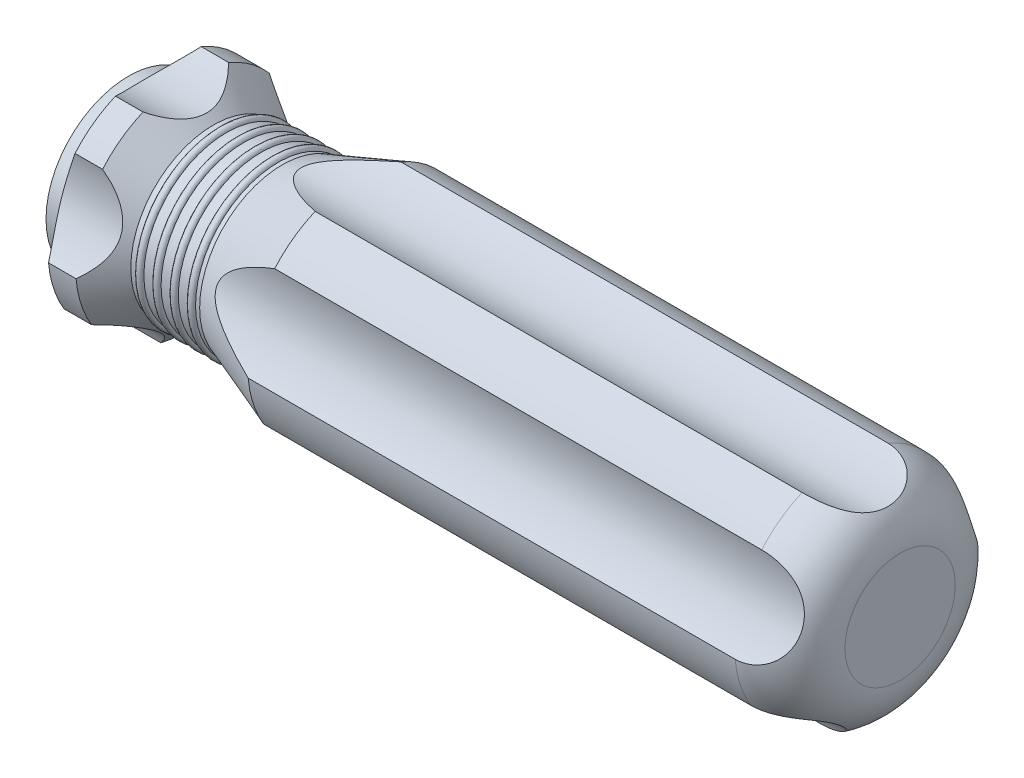
from build123d import *

# Parameters (mm, degrees)
SKETCH2_R          = 0.25
LPATTERN1_COUNT    = 4
LPATTERN1_PITCH    = 1.25
SKETCH3_R          = 6
CUT_EXTRUDE1_DEPTH = 57
CIRPATTERN1_COUNT  = 5
SKETCH4_R          = 1.5
CUT_EXTRUDE2_DEPTH = 30


with BuildPart() as part:
    # Sketch1 → Revolve1 (revolve)
    with BuildSketch(Plane.XY):
        with BuildLine():
            Line((0, 6), (1, 6))
            Line((1, 6), (2.154700538, 8))
            Line((2.154700538, 8), (4.154700538, 8))
            Line((4.154700538, 8), (6.154700538, 6))
            Line((6.154700538, 6), (11.154700538, 6))
            Line((11.154700538, 6), (16.649655377, 8))
            Line((16.649655377, 8), (52, 8))
            ThreePointArc((52, 8), (54.828427125, 6.828427125), (56, 4))
            Line((56, 4), (56, 0))
            Line((56, 0), (0, 0))
            Line((0, 0), (0, 6))
        make_face()
    revolve(axis=Axis((0, 0, 0), (1, 0, 0)))

    # Sketch2 → Revolve2 (revolve)
    with BuildSketch(Plane.XY):
        with Locations((6.854700538, 6)):
            Circle(SKETCH2_R)
    revolve2 = revolve(axis=Axis((0, 0, 0), (1, 0, 0)))

    # LPattern1: Revolve2 ×4
    with Locations(*[(i * LPATTERN1_PITCH, 0, 0) for i in range(1, LPATTERN1_COUNT)]):
        add(revolve2)

    # Sketch3 → Cut-Extrude1 (cut, through all)
    with BuildSketch(Plane.ZY):
        with Locations((0, 12.5)):
            Circle(SKETCH3_R)
    cut_extrude1 = extrude(amount=-CUT_EXTRUDE1_DEPTH, mode=Mode.SUBTRACT)

    # CirPattern1: Cut-Extrude1 ×5 about axis
    cirpattern1_axis = Axis((0, 0, 0), (1, 0, 0))
    for i in range(1, CIRPATTERN1_COUNT):
        add(cut_extrude1.rotate(cirpattern1_axis, i * 360 / CIRPATTERN1_COUNT), mode=Mode.SUBTRACT)

    # Sketch4 → Cut-Extrude2 (cut)
    with BuildSketch(Plane.ZY):
        Circle(SKETCH4_R)
    extrude(amount=-CUT_EXTRUDE2_DEPTH, mode=Mode.SUBTRACT)


solid = part.part
